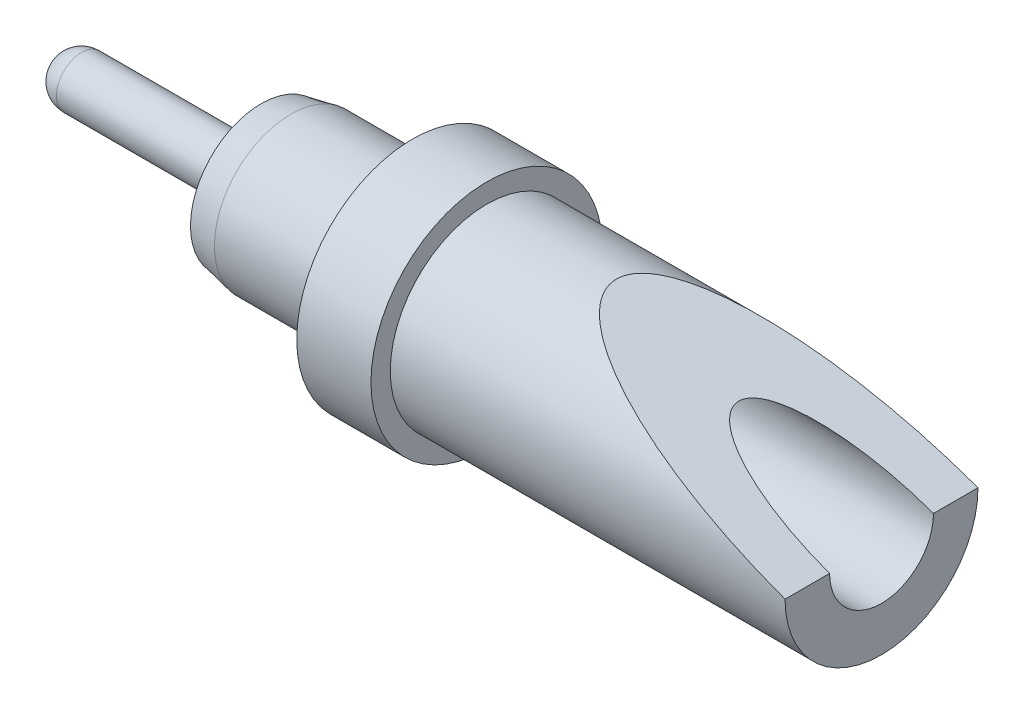
from build123d import *

# Parameters (mm, degrees)
HOLE1_D                 = 0.889
HOLE1_DEPTH             = 4.572
HOLE1_TIP               = 0.267082545
CUT_EXTRUDE1_DEPTH      = 0.889
CUT_EXTRUDE1_DEPTH_BACK = 0.889


with BuildPart() as part:
    # Sketch1 → RevolutionAngle1 (revolve)
    with BuildSketch(Plane.XY):
        with BuildLine():
            Line((0.2159, 0.2159), (1.6764, 0.2159))
            ThreePointArc((1.6764, 0.2159), (1.730281537, 0.238218463), (1.7526, 0.2921))
            Line((1.7526, 0.2921), (1.7526, 0.604677401))
            Line((1.7526, 0.604677401), (2.0066, 0.65405))
            Line((2.0066, 0.65405), (3.048, 0.65405))
            Line((3.048, 0.65405), (3.048, 0.9906))
            Line((3.048, 0.9906), (3.683, 0.9906))
            Line((3.683, 0.9906), (3.683, 0.8255))
            Line((3.683, 0.8255), (7.0612, 0.8255))
            Line((7.0612, 0.8255), (7.0612, 0))
            Line((7.0612, 0), (0, 0))
            ThreePointArc((0, 0), (0.063235646, 0.152664354), (0.2159, 0.2159))
        make_face()
    revolve(axis=Axis((0, 0, 0), (1, 0, 0)))

    # Hole1
    with Locations(Plane(origin=(7.0612, 0, 0), x_dir=(0, 0, 1), z_dir=(1, 0, 0))):
        with Locations((0, 0)):
            Hole(HOLE1_D / 2, depth=HOLE1_DEPTH)
            with Locations((0, 0, -(HOLE1_DEPTH + HOLE1_TIP / 2))):  # 118° drill point
                Cone(0, HOLE1_D / 2, HOLE1_TIP, mode=Mode.SUBTRACT)

    # Sketch3 → Cut-Extrude1 (cut, two sides: drawn at the far end of the back side and taken through both)
    with BuildSketch(Plane.XY.offset(-CUT_EXTRUDE1_DEPTH_BACK)):
        Polygon((7.0612, 0.8255), (7.0612, 0), (4.79315739, 0.8255), align=None)
    extrude(amount=CUT_EXTRUDE1_DEPTH + CUT_EXTRUDE1_DEPTH_BACK, mode=Mode.SUBTRACT)


solid = part.part
